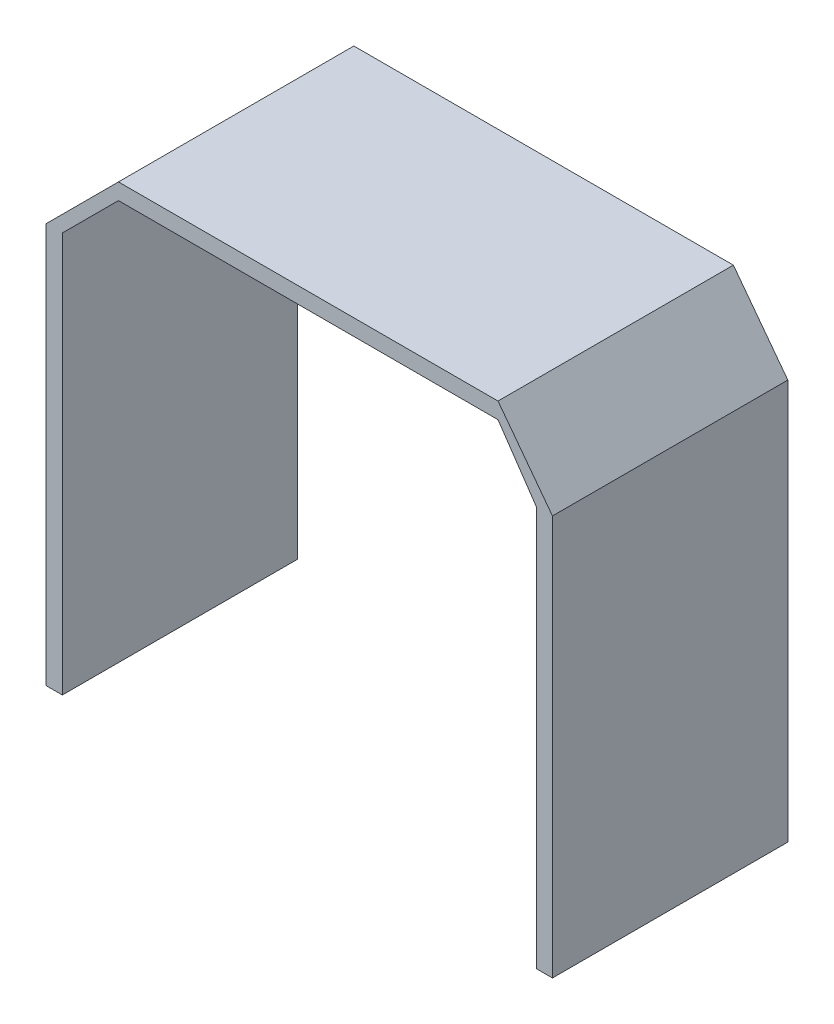
from build123d import *

# Parameters (mm, degrees)
BOSS_EXTRUDE1_DEPTH = 32


with BuildPart() as part:
    # Sketch1 → Boss-Extrude1 (new body)
    with BuildSketch(Plane.XY):
        Polygon((0, 0), (0, 54.4), (-5.201179862, 62.028885271), (-56.801179862, 62.028885271), (-64.430065133, 54.4), (-64.430065133, 0), (-66.630065133, 0), (-66.630065133, 54.4), (-56.801179862, 64.228885271), (-5.201179862, 64.228885271), (2.2, 54.4), (2.2, 0.000275755), align=None)
    extrude(amount=BOSS_EXTRUDE1_DEPTH)


solid = part.part
